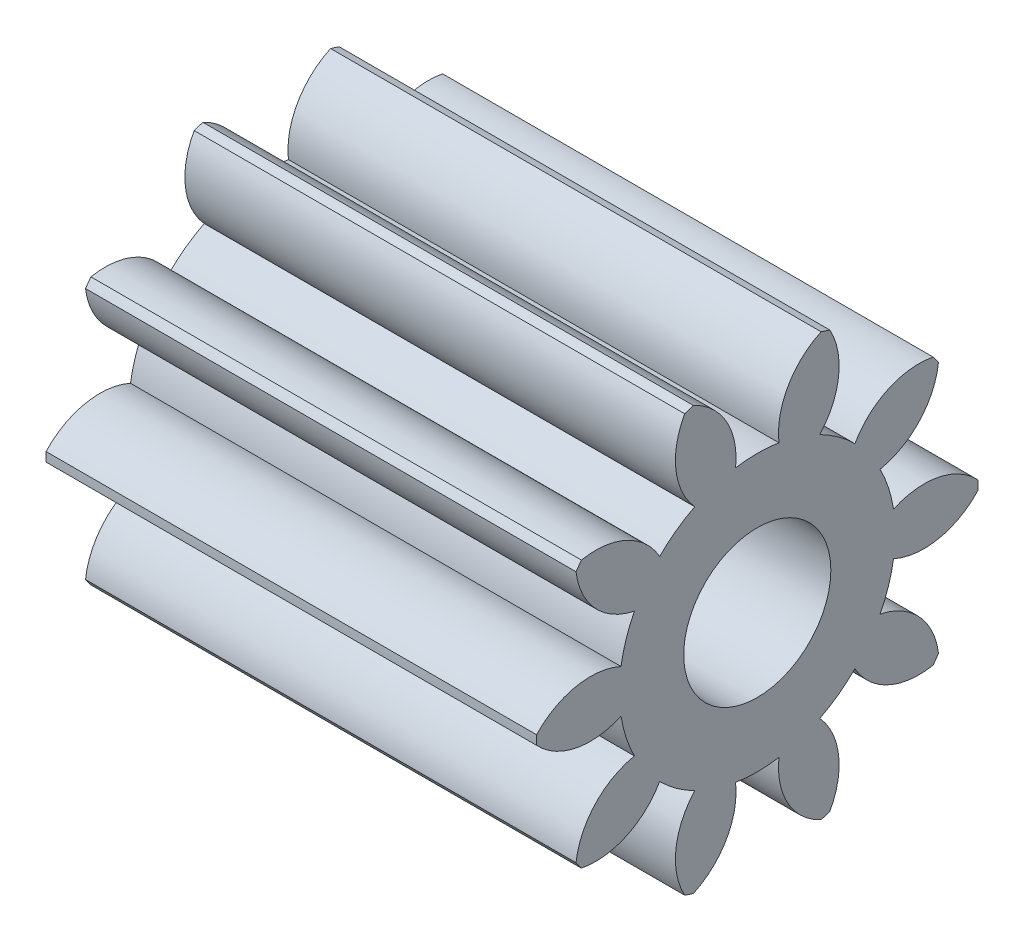
from build123d import *

# Parameters (mm, degrees)
BASPROSKE_W           = 20
BASPROSKE_H           = 9
TOOTHCUT_DEPTH        = 24.706539182
TEETHCUTS_COUNT       = 10
TEETHCUTS_ANGLE       = 324
BORSKE_R              = 2.5
BORE_DEPTH            = 50.0000508
IZIM1_R               = 3
KES_EKSTR_ZYON1_DEPTH = 26


with BuildPart() as part:
    # BasProSke → Base-Revolve (revolve)
    with BuildSketch(Plane(origin=(0, 0, 0), x_dir=(1, 0, 0), z_dir=(0, 1, 0)), mode=Mode.PRIVATE) as base_revolve_sk:
        with Locations((10, 4.5)):
            Rectangle(BASPROSKE_W, BASPROSKE_H)
    revolve(base_revolve_sk.sketch.rotate(Axis((-10, 0, 0), (1, 0, 0)), 180), axis=Axis((-10, 0, 0), (1, 0, 0)))

    # TooCutSke → ToothCut (cut, through all)
    with BuildSketch(Plane(origin=(0, 0, 0), x_dir=(0, 0, -1), z_dir=(1, 0, 0))):
        with BuildLine():
            ThreePointArc((0.883878355, 5.554109745), (0, 5.624), (-0.883878355, 5.554109745))
            ThreePointArc((-0.883878355, 5.554109745), (-1.258245767, 7.379188248), (-2.637816971, 8.631324741))
            ThreePointArc((-2.637816971, 8.631324741), (0, 9.0254), (2.637816971, 8.631324741))
            ThreePointArc((2.637816971, 8.631324741), (1.258245767, 7.379188248), (0.883878355, 5.554109745))
        make_face()
    toothcut = extrude(amount=TOOTHCUT_DEPTH, mode=Mode.SUBTRACT)

    # TeethCuts: ToothCut ×10 about axis
    teethcuts_axis = Axis((-10, 0, 0), (1, 0, 0))
    for i in range(1, TEETHCUTS_COUNT):
        add(toothcut.rotate(teethcuts_axis, i * TEETHCUTS_ANGLE / (TEETHCUTS_COUNT - 1)), mode=Mode.SUBTRACT)

    # BorSke → Bore (cut, symmetric)
    with BuildSketch(Plane(origin=(0, 0, 0), x_dir=(0, 0, -1), z_dir=(1, 0, 0))):
        with Locations(Location((0, 0, 0), (0, 0, 180))):
            Circle(BORSKE_R)
    extrude(amount=BORE_DEPTH, both=True, mode=Mode.SUBTRACT)

    # Çizim1 → Kes-Ekstrüzyon1 (cut)
    with BuildSketch(Plane(origin=(20, 0, 0), x_dir=(0, 0, -1), z_dir=(1, 0, 0))):
        Circle(IZIM1_R)
    extrude(amount=-KES_EKSTR_ZYON1_DEPTH, mode=Mode.SUBTRACT)


solid = part.part
